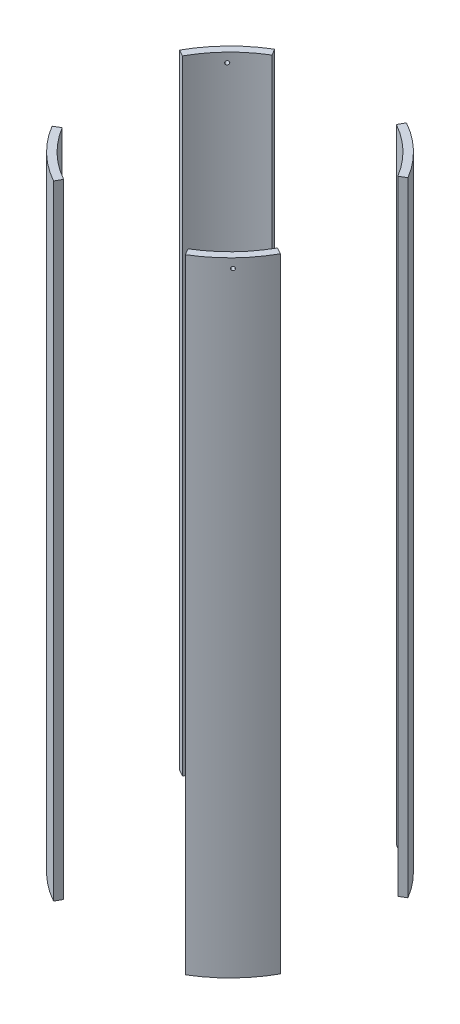
from build123d import *

# Parameters (mm, degrees)
SKETCH2_R               = 88.9
SKETCH2_R_2             = 83.82
BOSS_EXTRUDE1_DEPTH     = 213.6775
CUT_EXTRUDE1_DEPTH      = 214.6775
CUT_EXTRUDE1_DEPTH_BACK = 214.6775
SKETCH5_R               = 1.27
TOP_BOLT_HOLES_DEPTH    = 29.911624556
SKETCH6_R               = 1.27
BOTTOM_BOLT_HOLES_DEPTH = 31.75
BOLT_PATTERN_COUNT      = 4


with BuildPart() as part:
    # Sketch2 → Boss-Extrude1 (new body, symmetric)
    with BuildSketch(Plane(origin=(0, 0, 0), x_dir=(1, 0, 0), z_dir=(0, 1, 0))):
        Circle(SKETCH2_R)
        Circle(SKETCH2_R_2, mode=Mode.SUBTRACT)
    extrude(amount=BOSS_EXTRUDE1_DEPTH, both=True)

    # Sketch3 → Cut-Extrude1 (cut, two sides)
    with BuildSketch(Plane(origin=(0, 0, 0), x_dir=(1, 0, 0), z_dir=(0, 1, 0))) as cut_extrude1_sk:
        Polygon((169.661755759, -94.300371224), (0, 0), (169.661755759, 101.677593364), align=None)
        Polygon((0, 0), (53.900027233, 96.974944394), (-58.116685864, 96.974944394), align=None)
        Polygon((-123.741299607, 68.777140945), (-123.741299607, -74.157652604), (0, 0), align=None)
        Polygon((-65.840936026, -118.45858783), (0, 0), (70.991745134, -118.45858783), align=None)
    extrude(amount=CUT_EXTRUDE1_DEPTH, mode=Mode.SUBTRACT)
    extrude(cut_extrude1_sk.sketch, amount=-CUT_EXTRUDE1_DEPTH_BACK, mode=Mode.SUBTRACT)

    # Sketch5 → Top bolt holes (cut, through all)
    with BuildSketch(Plane(origin=(-56.309218645, 0, 58.175814955), x_dir=(-0.718540152, 0, -0.695485478), z_dir=(0.695485478, 0, -0.718540152))):
        with Locations((-0.02278764, 207.3275)):
            Circle(SKETCH5_R)
    top_bolt_holes = extrude(amount=-TOP_BOLT_HOLES_DEPTH, mode=Mode.SUBTRACT)

    # Sketch6 → Bottom bolt holes (cut)
    with BuildSketch(Plane(origin=(0, -213.6775, 0), x_dir=(-1, 0, 0), z_dir=(0, -1, 0))):
        with Locations((60.062125915, -62.053127484)):
            Circle(SKETCH6_R)
    bottom_bolt_holes = extrude(amount=-BOTTOM_BOLT_HOLES_DEPTH, mode=Mode.SUBTRACT)

    # Bolt pattern: Top bolt holes, Bottom bolt holes ×4 about axis
    bolt_pattern_axis = Axis((0, 0, 0), (0, 1, 0))
    for i in range(1, BOLT_PATTERN_COUNT):
        add(top_bolt_holes.rotate(bolt_pattern_axis, i * 360 / BOLT_PATTERN_COUNT), mode=Mode.SUBTRACT)
        add(bottom_bolt_holes.rotate(bolt_pattern_axis, i * 360 / BOLT_PATTERN_COUNT), mode=Mode.SUBTRACT)


solid = part.part
